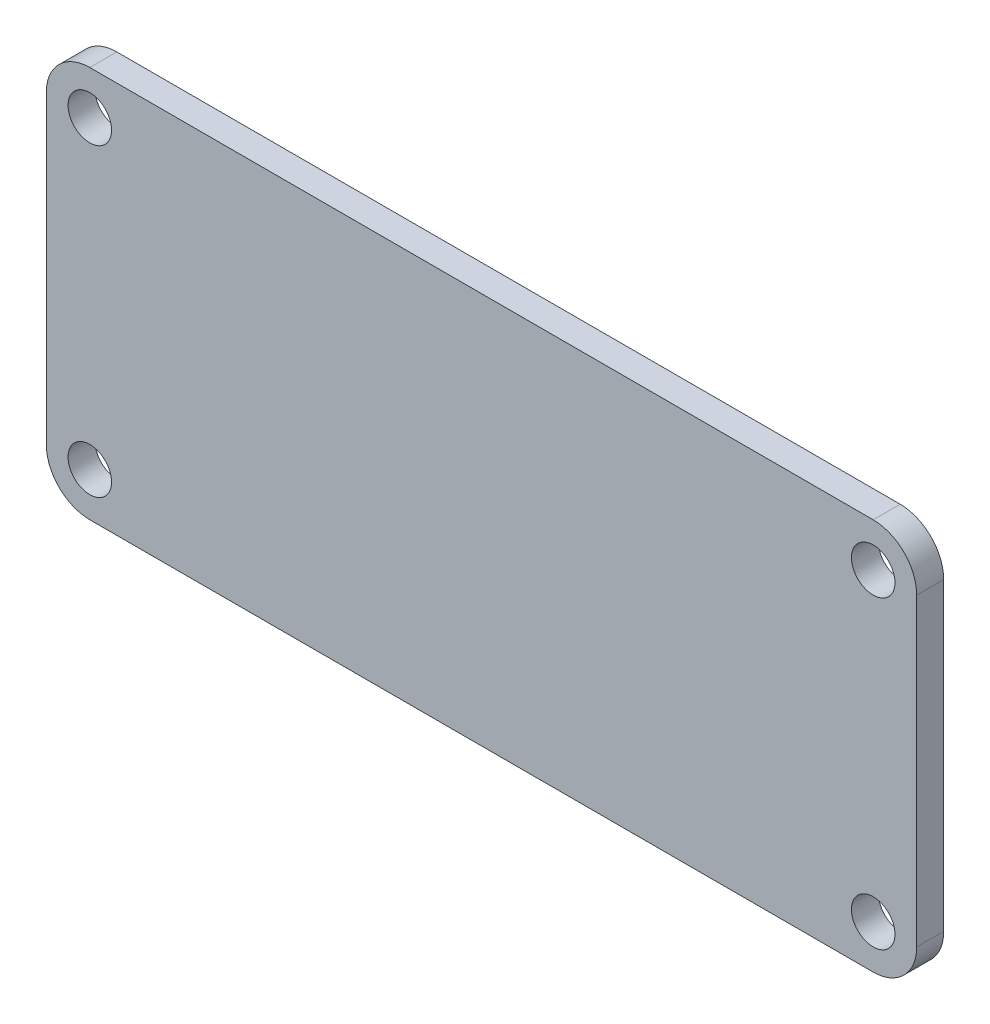
from build123d import *

# Parameters (mm, degrees)
SKETCH1_W           = 50.8
SKETCH1_H           = 22.86
BOSS_EXTRUDE1_DEPTH = 1.5748
SKETCH2_R           = 1.27
CUT_EXTRUDE1_DEPTH  = 2.5748
FILLET1_R           = 2.54


with BuildPart() as part:
    # Sketch1 → Boss-Extrude1 (new body)
    with BuildSketch(Plane.XY):
        Rectangle(SKETCH1_W, SKETCH1_H)
    extrude(amount=BOSS_EXTRUDE1_DEPTH)

    # Sketch2 → Cut-Extrude1 (cut, through all)
    with BuildSketch(Plane.XY.offset(1.5748)):
        with Locations((-22.86, 8.89)):
            Circle(SKETCH2_R)
        with Locations((22.86, 8.89)):
            Circle(SKETCH2_R)
        with Locations((-22.86, -8.89)):
            Circle(SKETCH2_R)
        with Locations((22.86, -8.89)):
            Circle(SKETCH2_R)
    extrude(amount=-CUT_EXTRUDE1_DEPTH, mode=Mode.SUBTRACT)

    # Fillet1
    fillet1_edges = [part.edges().sort_by_distance(p)[0] for p in [
        (-25.4, 11.43, 0.7874),
        (25.4, 11.43, 0.7874),
        (25.4, -11.43, 0.7874),
        (-25.4, -11.43, 0.7874),
    ]]
    fillet(fillet1_edges, radius=FILLET1_R)


solid = part.part
